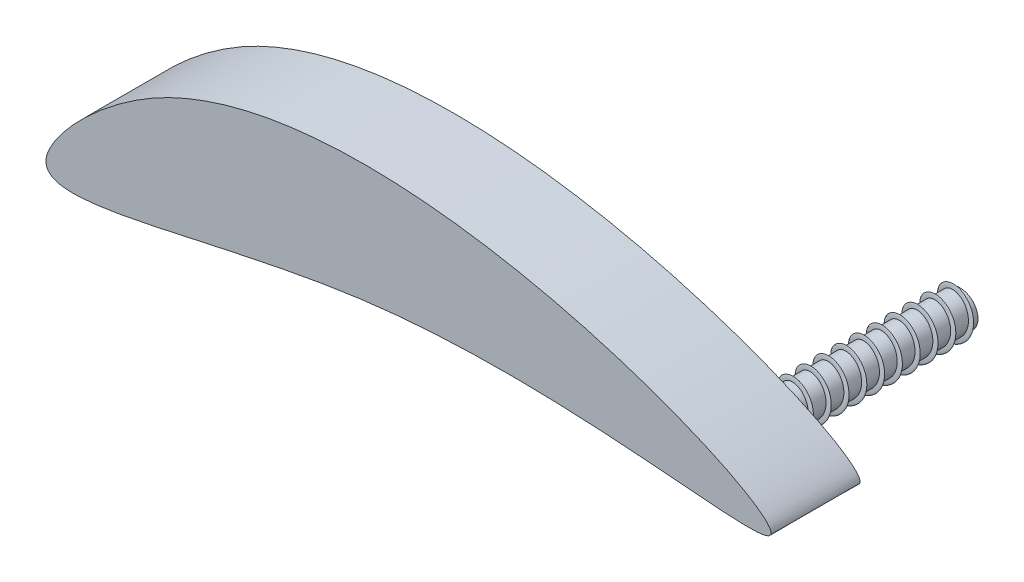
from build123d import *

# Parameters (mm, degrees)
BOSS_EXTRUDE1_DEPTH = 5
SKETCH6_R           = 1
BOSS_EXTRUDE2_DEPTH = 10
SWEEP1_PITCH        = 1
SWEEP1_HEIGHT       = 10
SWEEP1_RADIUS       = 1
SWEEP1_START_ANGLE  = 135
SKETCH8_R           = 0.25


with BuildPart() as part:
    # Sketch1 → Boss-Extrude1 (new body)
    with BuildSketch(Plane.XY):
        with BuildLine():
            add(Edge.make_bspline(
                [(0, 0), (0.337869349, 1.332329851), (13.566957324, 15.446694578), (56.410051611, -2.891511289), (20.931893871, 5.282605428), (-0.727618154, -2.869237446), (0, 0)],
                knots=[0, 0, 0, 0, 0.099435015, 0.514725265, 0.785861836, 1, 1, 1, 1], degree=3))
        make_face()
    extrude(amount=-BOSS_EXTRUDE1_DEPTH)

    # Sketch6 → Boss-Extrude2 (add)
    with BuildSketch(Plane(origin=(0, 0, -5), x_dir=(-1, 0, 0), z_dir=(0, 0, -1))):
        with Locations(Location((-36.330231663, 3.234152611, 0), (0, 0, 180))):
            Circle(SKETCH6_R)
    extrude(amount=BOSS_EXTRUDE2_DEPTH)

    # Sweep1: sweep along a helix
    with BuildLine() as sweep1_path:
        add(Helix(SWEEP1_PITCH, SWEEP1_HEIGHT, SWEEP1_RADIUS, center=(36.330231663, 3.234152611, -5), direction=(0, 0, -1), lefthand=True, mode=Mode.PRIVATE).rotate(Axis((36.330231663, 3.234152611, -5), (0, 0, -1)), SWEEP1_START_ANGLE))
    # Sketch8 → Sweep1 (sweep)
    with BuildSketch(Plane(origin=(0, 0, -5), x_dir=(-1, 0, 0), z_dir=(0, 0, -1))):
        with Locations((-35.33249818, 3.166862968)):
            Circle(SKETCH8_R)
    sweep(path=sweep1_path.line, is_frenet=True)


solid = part.part
